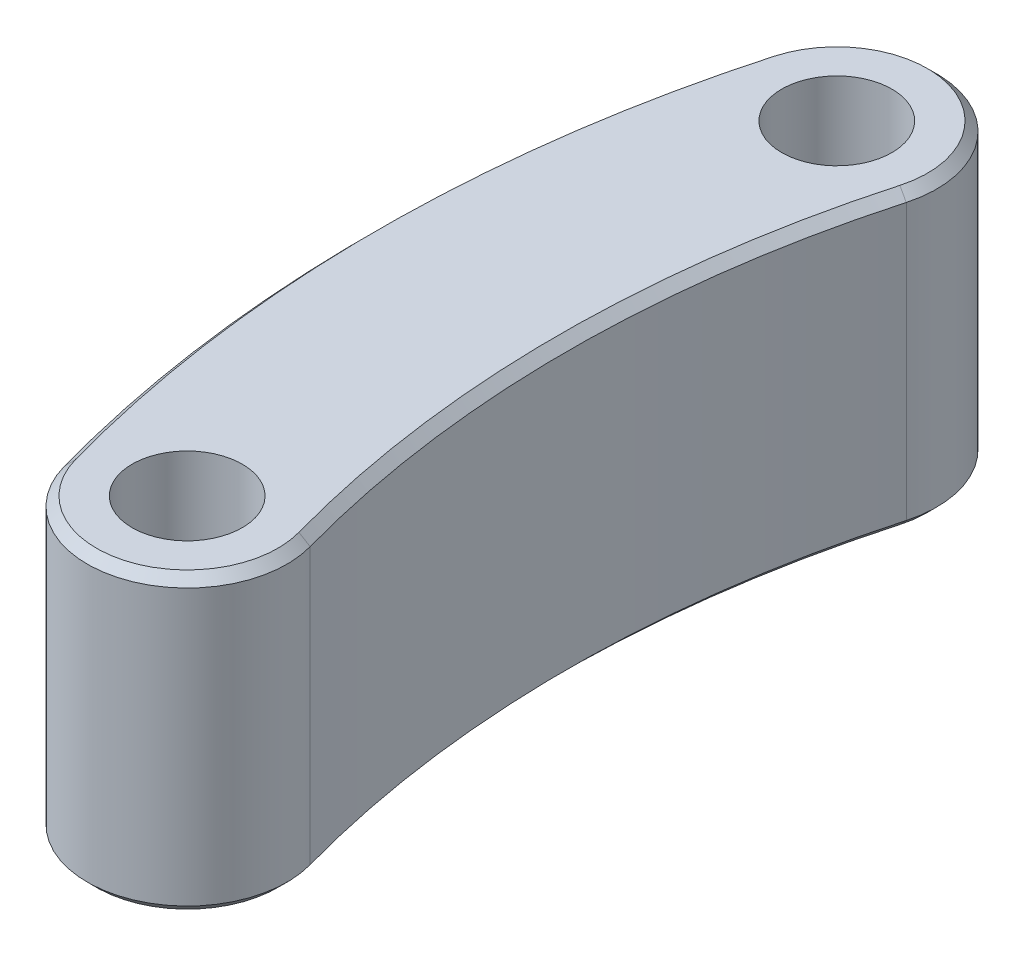
from build123d import *

# Parameters (mm, degrees)
SKETCH_1_R      = 3
EXTRUDE_1_DEPTH = 16
CHAMFER_1_SIZE  = 0.5


with BuildPart() as part:
    # 草图1 → 凸台-拉伸1 (new body)
    with BuildSketch(Plane(origin=(0, 0, 0), x_dir=(1, 0, 0), z_dir=(0, 1, 0))):
        with BuildLine():
            ThreePointArc((-5.240891545, 36.838305804), (1.458305804, 40.620891545), (5.240891545, 33.921694196))
            ThreePointArc((5.240891545, 33.921694196), (3.024711954, 17.69), (5.240891545, 1.458305804))
            ThreePointArc((5.240891545, 1.458305804), (1.458305804, -5.240891545), (-5.240891545, -1.458305804))
            ThreePointArc((-5.240891545, -1.458305804), (-7.855288046, 17.69), (-5.240891545, 36.838305804))
        make_face()
        Circle(SKETCH_1_R, mode=Mode.SUBTRACT)
        with Locations((0, 35.38)):
            Circle(SKETCH_1_R, mode=Mode.SUBTRACT)
    extrude(amount=EXTRUDE_1_DEPTH)

    # 倒角1
    chamfer_1_edges = [part.edges().sort_by_distance(p)[0] for p in [
        (3.024711954, 16, -17.69),
        (1.458305804, 16, -40.620891545),
        (-7.855288046, 16, -17.69),
        (1.458305804, 0, -40.620891545),
        (3.024711954, 0, -17.69),
        (1.458305804, 0, 5.240891545),
        (-7.855288046, 0, -17.69),
        (1.458305804, 16, 5.240891545),
    ]]
    chamfer(chamfer_1_edges, length=CHAMFER_1_SIZE)


solid = part.part
